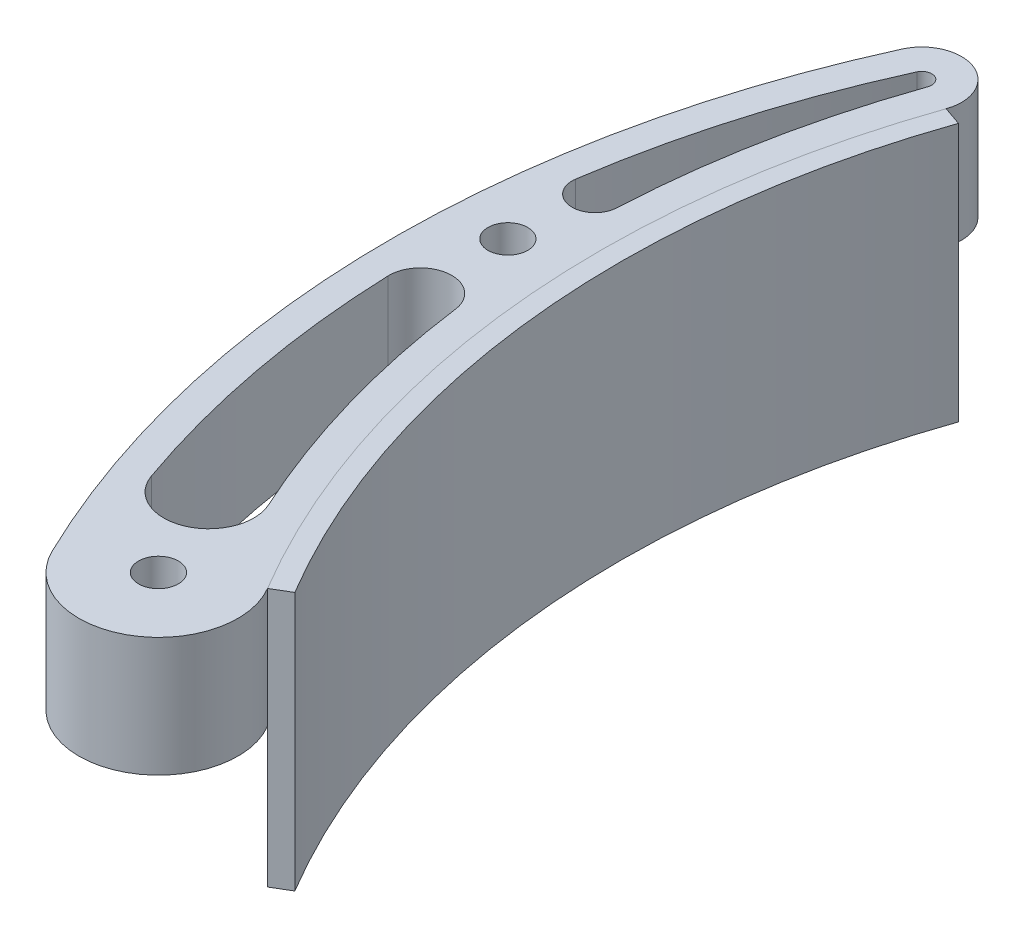
from build123d import *

# Parameters (mm, degrees)
SKETCH1_R           = 3.175
BOSS_EXTRUDE1_DEPTH = 19.05
CUT_EXTRUDE1_DEPTH  = 20.05
CUT_EXTRUDE2_DEPTH  = 20.05
BOSS_EXTRUDE2_DEPTH = 41.275


with BuildPart() as part:
    # Sketch1 → Boss-Extrude1 (new body)
    with BuildSketch(Plane(origin=(0, 0, 0), x_dir=(1, 0, 0), z_dir=(0, 1, 0))):
        with BuildLine():
            ThreePointArc((-135.252327308, 47.213234308), (-142.533412468, -14.370381558), (-123.105955958, -73.261211726))
            ThreePointArc((-123.105955958, -73.261211726), (-128.003817931, -90.940825055), (-145.454595651, -85.28148443))
            ThreePointArc((-145.454595651, -85.28148443), (-161.535072193, -16.847470136), (-147.026852029, 51.937030923))
            ThreePointArc((-147.026852029, 51.937030923), (-138.883189966, 55.199429393), (-135.252327308, 47.213234308))
        make_face()
        with Locations((-134.019604536, -79.756)):
            Circle(SKETCH1_R, mode=Mode.SUBTRACT)
        with Locations((-152.238831544, -5.766137402)):
            Circle(SKETCH1_R, mode=Mode.SUBTRACT)
    extrude(amount=BOSS_EXTRUDE1_DEPTH)

    # Sketch2 → Cut-Extrude1 (cut, through all)
    with BuildSketch(Plane(origin=(0, 19.05, 0), x_dir=(1, 0, 0), z_dir=(0, 1, 0))):
        with BuildLine():
            ThreePointArc((-142.692378944, 49.963772368), (-140.656463428, 50.779371986), (-139.748747763, 48.782823215))
            ThreePointArc((-139.748747763, 48.782823215), (-145.29042963, 28.287230336), (-147.842813364, 7.209637907))
            ThreePointArc((-147.842813364, 7.209637907), (-151.84450431, 3.75488539), (-155.099163962, 7.920942989))
            ThreePointArc((-155.099163962, 7.920942989), (-150.372373234, 29.37810097), (-142.692378944, 49.963772368))
        make_face()
    extrude(amount=-CUT_EXTRUDE1_DEPTH, mode=Mode.SUBTRACT)

    # Sketch3 → Cut-Extrude2 (cut, through all)
    with BuildSketch(Plane(origin=(0, 19.05, 0), x_dir=(1, 0, 0), z_dir=(0, 1, 0))):
        with BuildLine():
            ThreePointArc((-146.711397823, -19.627584953), (-142.204584096, -41.077154288), (-134.579739329, -61.626050533))
            ThreePointArc((-134.579739329, -61.626050533), (-138.426335153, -71.290308551), (-147.905040723, -67.006814278))
            ThreePointArc((-147.905040723, -67.006814278), (-154.06386253, -44.070471811), (-156.687709885, -20.467033144))
            ThreePointArc((-156.687709885, -20.467033144), (-152.099180348, -15.298000327), (-146.711397823, -19.627584953))
        make_face()
    extrude(amount=-CUT_EXTRUDE2_DEPTH, mode=Mode.SUBTRACT)


with BuildPart() as body_2:
    # Sketch4 → Boss-Extrude2 (new body)
    with BuildSketch(Plane(origin=(0, 19.05, 0), x_dir=(1, 0, 0), z_dir=(0, 1, 0))):
        with BuildLine():
            Line((-135.252327308, 47.213234308), (-132.254713671, 46.166841704))
            ThreePointArc((-132.254713671, 46.166841704), (-139.374427263, -14.051889059), (-120.377543814, -71.637514658))
            Line((-120.377543814, -71.637514658), (-123.105955958, -73.261211726))
            ThreePointArc((-123.105955958, -73.261211726), (-142.533412468, -14.370381558), (-135.252327308, 47.213234308))
        make_face()
    extrude(amount=-BOSS_EXTRUDE2_DEPTH)


solid = Compound([part.part, body_2.part])
